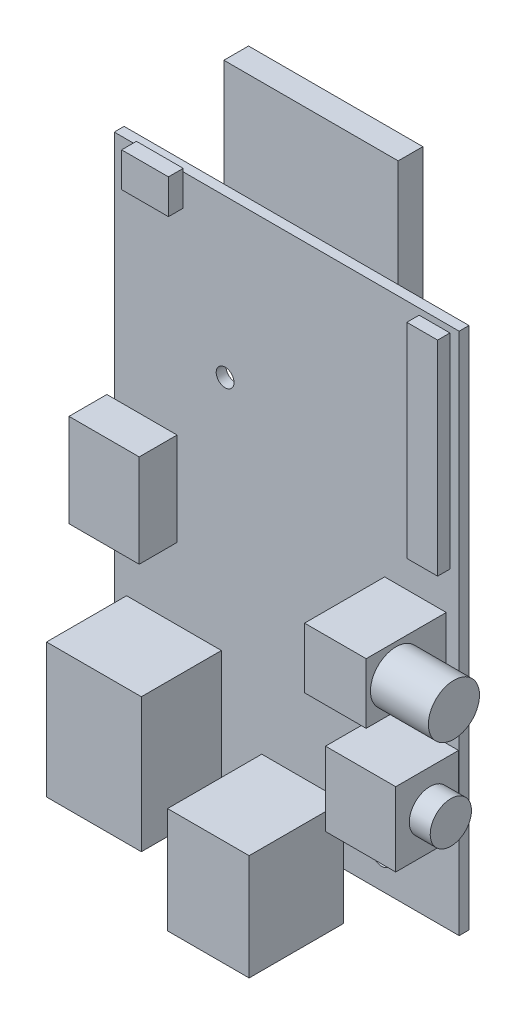
from build123d import *

# Parameters (mm, degrees)
CROQUIS1_W               = 56
CROQUIS1_H               = 85
CROQUIS1_R               = 1.45
SALIENTE_EXTRUIR1_DEPTH  = 1.6
CROQUIS2_W               = 7.6
CROQUIS2_H               = 5.6
SALIENTE_EXTRUIR2_DEPTH  = 2.4
CROQUIS3_W               = 11.4
CROQUIS3_H               = 15.1
SALIENTE_EXTRUIR3_DEPTH  = 6.15
CROQUIS4_W               = 15.4
CROQUIS4_H               = 21.8
SALIENTE_EXTRUIR4_DEPTH  = 13
CROQUIS5_W               = 13.25
CROQUIS5_H               = 17.2
SALIENTE_EXTRUIR5_DEPTH  = 15.3
CROQUIS6_W               = 11.4
CROQUIS6_H               = 12
SALIENTE_EXTRUIR6_DEPTH  = 10.2
CROQUIS7_W               = 10
CROQUIS7_H               = 9.8
SALIENTE_EXTRUIR7_DEPTH  = 13
CROQUIS8_W               = 5
CROQUIS8_H               = 33.2
SALIENTE_EXTRUIR8_DEPTH  = 2
CROQUIS10_W              = 28.3
CROQUIS10_H              = 35.1
SALIENTE_EXTRUIR9_DEPTH  = 4
CROQUIS11_R              = 3.35
SALIENTE_EXTRUIR10_DEPTH = 3.4
CROQUIS12_R              = 4.15
SALIENTE_EXTRUIR11_DEPTH = 9.4


with BuildPart() as part:
    # Croquis1 → Saliente-Extruir1 (new body)
    with BuildSketch(Plane.XY):
        with Locations((28, 42.5)):
            Rectangle(CROQUIS1_W, CROQUIS1_H)
        with Locations((43.4, 4.9)):
            Circle(CROQUIS1_R, mode=Mode.SUBTRACT)
        with Locations((18, 59.5)):
            Circle(CROQUIS1_R, mode=Mode.SUBTRACT)
    extrude(amount=SALIENTE_EXTRUIR1_DEPTH)

    # Croquis2 → Saliente-Extruir2 (add)
    with BuildSketch(Plane.XY.offset(1.6)):
        with Locations((7.4, 82.7)):
            Rectangle(CROQUIS2_W, CROQUIS2_H)
    extrude(amount=SALIENTE_EXTRUIR2_DEPTH)

    # Croquis3 → Saliente-Extruir3 (add)
    with BuildSketch(Plane.XY.offset(1.6)):
        with Locations((4.5, 39.95)):
            Rectangle(CROQUIS3_W, CROQUIS3_H)
    extrude(amount=SALIENTE_EXTRUIR3_DEPTH)

    # Croquis4 → Saliente-Extruir4 (add)
    with BuildSketch(Plane.XY.offset(1.6)):
        with Locations((9.7, 9.9)):
            Rectangle(CROQUIS4_W, CROQUIS4_H)
    extrude(amount=SALIENTE_EXTRUIR4_DEPTH)

    # Croquis5 → Saliente-Extruir5 (add)
    with BuildSketch(Plane.XY.offset(1.6)):
        with Locations((30.575, 0.9)):
            Rectangle(CROQUIS5_W, CROQUIS5_H)
    extrude(amount=SALIENTE_EXTRUIR5_DEPTH)

    # Croquis6 → Saliente-Extruir6 (add)
    with BuildSketch(Plane.XY.offset(1.6)):
        with Locations((50.2, 20)):
            Rectangle(CROQUIS6_W, CROQUIS6_H)
    extrude(amount=SALIENTE_EXTRUIR6_DEPTH)

    # Croquis7 → Saliente-Extruir7 (add)
    with BuildSketch(Plane.XY.offset(1.6)):
        with Locations((48.9, 39.5)):
            Rectangle(CROQUIS7_W, CROQUIS7_H)
    extrude(amount=SALIENTE_EXTRUIR7_DEPTH)

    # Croquis8 → Saliente-Extruir8 (add)
    with BuildSketch(Plane.XY.offset(1.6)):
        with Locations((52, 67.4)):
            Rectangle(CROQUIS8_W, CROQUIS8_H)
    extrude(amount=SALIENTE_EXTRUIR8_DEPTH)

    # Croquis10 → Saliente-Extruir9 (add)
    with BuildSketch(Plane(origin=(0, 0, 0), x_dir=(-1, 0, 0), z_dir=(0, 0, -1))):
        with Locations((-30.35, 84.85)):
            Rectangle(CROQUIS10_W, CROQUIS10_H)
    extrude(amount=SALIENTE_EXTRUIR9_DEPTH)

    # Croquis12 → Saliente-Extruir11 (add)
    with BuildSketch(Plane(origin=(53.9, 0, 0), x_dir=(0, 0, -1), z_dir=(1, 0, 0))):
        with Locations((-9.75, 39.5)):
            Circle(CROQUIS12_R)
    extrude(amount=SALIENTE_EXTRUIR11_DEPTH)


with BuildPart() as body_2:
    # Croquis11 → Saliente-Extruir10 (new body)
    with BuildSketch(Plane(origin=(56, 0, 0), x_dir=(0, 0, -1), z_dir=(1, 0, 0))):
        with Locations((-6.35, 20)):
            Circle(CROQUIS11_R)
    extrude(amount=SALIENTE_EXTRUIR10_DEPTH)


solid = Compound([part.part, body_2.part])
